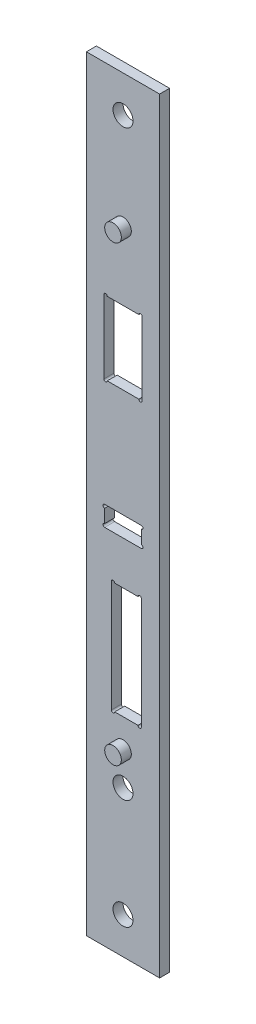
from build123d import *

# Parameters (mm, degrees)
ESQUISSE1_W                       = 22
ESQUISSE1_H                       = 230
EXTRUSION1_DEPTH                  = 1.5
DIAM_TRE_DU_PER_AGE_6_0_6_1_D     = 6
DIAM_TRE_DU_PER_AGE_6_0_6_1_DEPTH = 3
DIAM_TRE_DU_PER_AGE_6_0_6_1_TIP   = 1.802581857
ENL_V_MAT_EXTRU_1_REACH           = 5
ENL_V_MAT_EXTRU_2_REACH           = 5
ENL_V_MAT_EXTRU_3_REACH           = 5
ESQUISSE10_R                      = 2.5
EXTRUSION2_DEPTH                  = 3


with BuildPart() as part:
    # Esquisse1 → Extrusion1 (new body, symmetric)
    with BuildSketch(Plane.XY):
        Rectangle(ESQUISSE1_W, ESQUISSE1_H)
    extrude(amount=EXTRUSION1_DEPTH, both=True)

    # Diamètre du perçage Ø6.0 (6)1
    with Locations(Plane.XY.offset(1.5)):
        with Locations((0, 104), (0, -71), (0, -104)):
            Hole(DIAM_TRE_DU_PER_AGE_6_0_6_1_D / 2, depth=DIAM_TRE_DU_PER_AGE_6_0_6_1_DEPTH)
            with Locations((0, 0, -(DIAM_TRE_DU_PER_AGE_6_0_6_1_DEPTH + DIAM_TRE_DU_PER_AGE_6_0_6_1_TIP / 2))):  # 118° drill point
                Cone(0, DIAM_TRE_DU_PER_AGE_6_0_6_1_D / 2, DIAM_TRE_DU_PER_AGE_6_0_6_1_TIP, mode=Mode.SUBTRACT)

    # Esquisse7 → Enlèv. mat.-Extru.1 (cut, up to next)
    with BuildSketch(Plane.XY.offset(1.5), mode=Mode.PRIVATE) as enl_v_mat_extru_1_sk1:
        with BuildLine():
            Line((-4.75, 54.5), (4.75, 54.5))
            ThreePointArc((4.75, 54.5), (5.25, 55), (5.75, 54.5))
            Line((5.75, 54.5), (5.75, 32.5))
            ThreePointArc((5.75, 32.5), (5.25, 32), (4.75, 32.5))
            Line((4.75, 32.5), (-4.75, 32.5))
            ThreePointArc((-4.75, 32.5), (-5.25, 32), (-5.75, 32.5))
            Line((-5.75, 32.5), (-5.75, 54.5))
            ThreePointArc((-5.75, 54.5), (-5.25, 55), (-4.75, 54.5))
        make_face()
    enl_v_mat_extru_1_tool1 = extrude(enl_v_mat_extru_1_sk1.sketch, amount=-ENL_V_MAT_EXTRU_1_REACH, mode=Mode.PRIVATE) & part.part
    add(enl_v_mat_extru_1_tool1.solids().sort_by_distance((0, 43.5, 1.5))[0], mode=Mode.SUBTRACT)

    # Esquisse8 → Enlèv. mat.-Extru.2 (cut, up to next)
    with BuildSketch(Plane.XY.offset(1.5), mode=Mode.PRIVATE) as enl_v_mat_extru_2_sk1:
        with BuildLine():
            Line((-5.5, 0), (5.5, 0))
            ThreePointArc((5.5, 0), (6, -0.5), (5.5, -1))
            Line((5.5, -1), (5.5, -5))
            ThreePointArc((5.5, -5), (6, -5.5), (5.5, -6))
            Line((5.5, -6), (-5.5, -6))
            ThreePointArc((-5.5, -6), (-6, -5.5), (-5.5, -5))
            Line((-5.5, -5), (-5.5, -1))
            ThreePointArc((-5.5, -1), (-6, -0.5), (-5.5, 0))
        make_face()
    enl_v_mat_extru_2_tool1 = extrude(enl_v_mat_extru_2_sk1.sketch, amount=-ENL_V_MAT_EXTRU_2_REACH, mode=Mode.PRIVATE) & part.part
    add(enl_v_mat_extru_2_tool1.solids().sort_by_distance((0, -3, 1.5))[0], mode=Mode.SUBTRACT)

    # Esquisse9 → Enlèv. mat.-Extru.3 (cut, up to next)
    with BuildSketch(Plane.XY.offset(1.5), mode=Mode.PRIVATE) as enl_v_mat_extru_3_sk1:
        with BuildLine():
            Line((-2.5, -19), (4.5, -19))
            ThreePointArc((4.5, -19), (5, -18.5), (5.5, -19))
            Line((5.5, -19), (5.5, -52.5))
            ThreePointArc((5.5, -52.5), (5, -53), (4.5, -52.5))
            Line((4.5, -52.5), (-2.5, -52.5))
            ThreePointArc((-2.5, -52.5), (-3, -53), (-3.5, -52.5))
            Line((-3.5, -52.5), (-3.5, -19))
            ThreePointArc((-3.5, -19), (-3, -18.5), (-2.5, -19))
        make_face()
    enl_v_mat_extru_3_tool1 = extrude(enl_v_mat_extru_3_sk1.sketch, amount=-ENL_V_MAT_EXTRU_3_REACH, mode=Mode.PRIVATE) & part.part
    add(enl_v_mat_extru_3_tool1.solids().sort_by_distance((1, -35.75, 1.5))[0], mode=Mode.SUBTRACT)

    # Esquisse10 → Extrusion2 (add)
    with BuildSketch(Plane.XY.offset(1.5)):
        with Locations((0, 75)):
            Circle(ESQUISSE10_R)
        with Locations((0, -61)):
            Circle(ESQUISSE10_R)
    extrude(amount=EXTRUSION2_DEPTH)


solid = part.part
